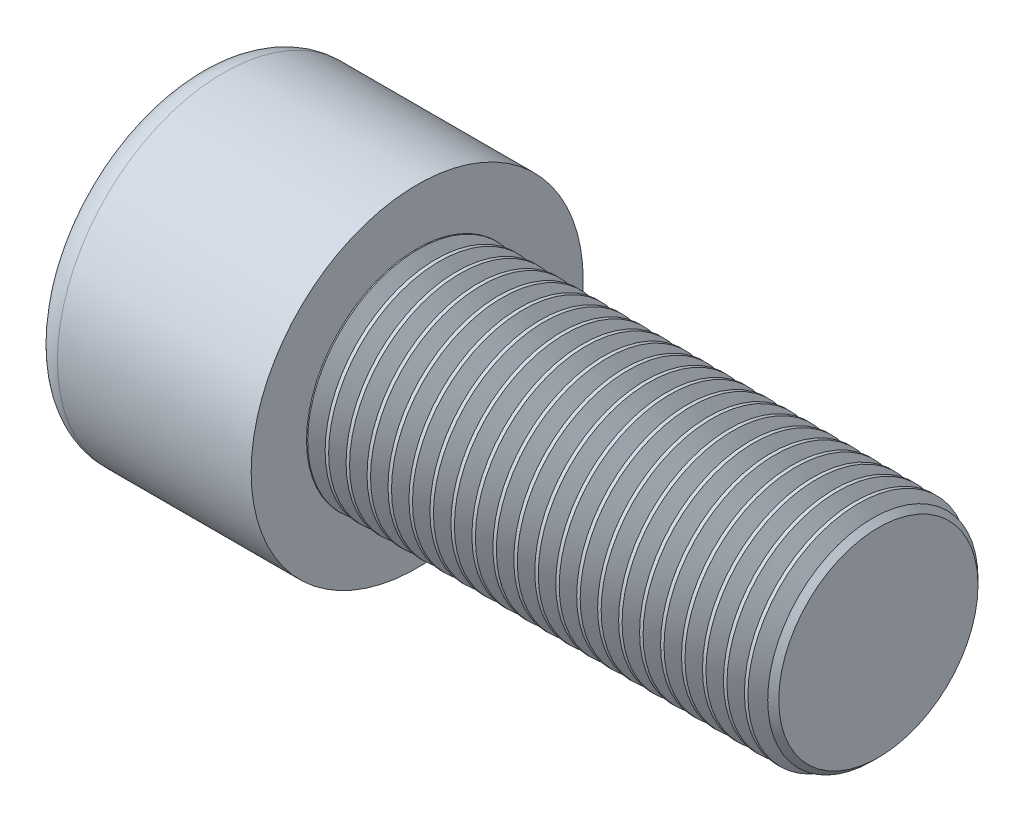
from build123d import *

# Parameters (mm, degrees)
SKETCH1_R           = 9
BASEHEAD_DEPTH      = 12
SKETCH2_R           = 6
BASEBODY_DEPTH      = 25
HEXAGONSOCKET_DEPTH = 6
TOPFILLET_R         = 1.5
CHAMFER1_SIZE       = 0.6
LPATTERN10_COUNT    = 22
LPATTERN10_PITCH    = 1.1364


with BuildPart() as part:
    # Sketch1 → BaseHead (new body)
    with BuildSketch(Plane(origin=(0, 0, 0), x_dir=(0, 0, -1), z_dir=(1, 0, 0))):
        Circle(SKETCH1_R)
    extrude(amount=BASEHEAD_DEPTH)

    # Sketch2 → BaseBody (add)
    with BuildSketch(Plane(origin=(12, 0, 0), x_dir=(0, 0, -1), z_dir=(1, 0, 0))):
        Circle(SKETCH2_R)
    extrude(amount=BASEBODY_DEPTH)

    # Sketch3 → HexagonSocket (cut)
    with BuildSketch(Plane(origin=(0, 0, 0), x_dir=(0, 0, -1), z_dir=(1, 0, 0))):
        Polygon((5.773502692, 0), (2.886751346, 5), (-2.886751346, 5), (-5.773502692, 0), (-2.886751346, -5), (2.886751346, -5), align=None)
    extrude(amount=HEXAGONSOCKET_DEPTH, mode=Mode.SUBTRACT)

    # Sketch4 → Cut-Revolve1 (revolve, cut)
    with BuildSketch(Plane(origin=(-4.19613823, 0.75, 0), x_dir=(-1, 0, 0), z_dir=(0, 0, 1))):
        Polygon((-10.19613823, 5.75), (-13.082889576, 0.75), (-10.19613823, 0.75), align=None)
    revolve(axis=Axis((0.838992387, 0, 0), (-1, 0, 0)), mode=Mode.SUBTRACT)

    # TopFillet
    topfillet_edges = [part.edges().sort_by_distance(p)[0] for p in [
        (0, 0, 9),
    ]]
    fillet(topfillet_edges, radius=TOPFILLET_R)

    # Chamfer1
    chamfer1_edges = [part.edges().sort_by_distance(p)[0] for p in [
        (37, 0, 6),
    ]]
    chamfer(chamfer1_edges, length=CHAMFER1_SIZE)

    # Sketch5 → Cut-Revolve10 (revolve, cut)
    with BuildSketch(Plane.XY):
        Polygon((36.4, 5.179873943), (36.8735, 6), (36.8735, 6.947), (35.9265, 6.947), (35.9265, 6), align=None)
    cut_revolve10 = revolve(axis=Axis((0, 0, 0), (1, 0, 0)), mode=Mode.SUBTRACT)

    # LPattern10: Cut-Revolve10 ×22
    with Locations(*[(-i * LPATTERN10_PITCH, 0, 0) for i in range(1, LPATTERN10_COUNT)]):
        add(cut_revolve10, mode=Mode.SUBTRACT)


solid = part.part
